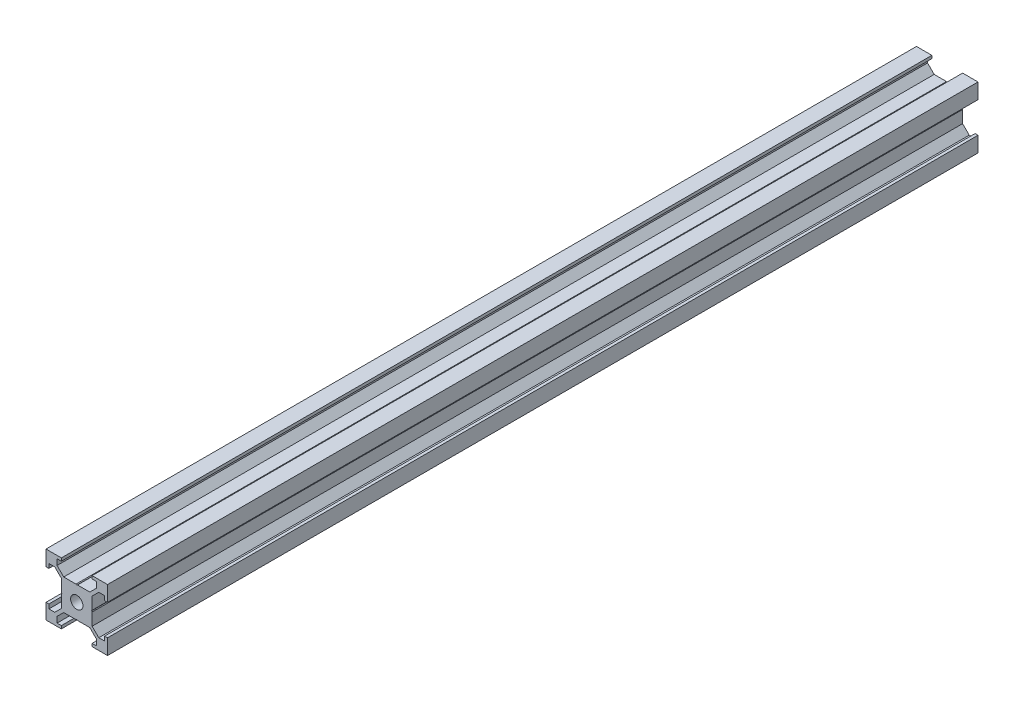
from build123d import *

# Parameters (mm, degrees)
SKETCH1_R           = 2
BOSS_EXTRUDE1_DEPTH = 283


with BuildPart() as part:
    # Sketch1 → Boss-Extrude1 (new body)
    with BuildSketch(Plane.XY):
        Polygon((6.4, 7.156263811), (4.243736189, 5), (5, 5), (5, 4.243736189), (7.156263811, 6.4), (9.056263811, 6.4), (9.056263811, 5), (10, 5), (10, 10), (5, 10), (5, 9.056263811), (6.4, 9.056263811), align=None)
        Polygon((-5, 0.245745613), (-5, 5), (-0.245745613, 5), (0, 4.827927069), (0.245745613, 5), (5, 5), (5, 0.245745613), (4.827927069, 0), (5, -0.245745613), (5, -5), (0.245745613, -5), (0, -4.827927069), (-0.245745613, -5), (-5, -5), (-5, -0.245745613), (-4.827927069, 0), align=None)
        Circle(SKETCH1_R, mode=Mode.SUBTRACT)
        Polygon((-10, 10), (-10, 5), (-9.056263811, 5), (-9.056263811, 6.4), (-7.156263811, 6.4), (-5, 4.243736189), (-5, 5), (-4.243736189, 5), (-6.4, 7.156263811), (-6.4, 9.056263811), (-5, 9.056263811), (-5, 10), align=None)
        Polygon((-5, -5), (-5, -4.243736189), (-7.156263811, -6.4), (-9.056263811, -6.4), (-9.056263811, -5), (-10, -5), (-10, -10), (-5, -10), (-5, -9.056263811), (-6.4, -9.056263811), (-6.4, -7.156263811), (-4.243736189, -5), align=None)
        Polygon((5, -5), (4.243736189, -5), (6.4, -7.156263811), (6.4, -9.056263811), (5, -9.056263811), (5, -10), (10, -10), (10, -5), (9.056263811, -5), (9.056263811, -6.4), (7.156263811, -6.4), (5, -4.243736189), align=None)
    extrude(amount=BOSS_EXTRUDE1_DEPTH)


solid = part.part
